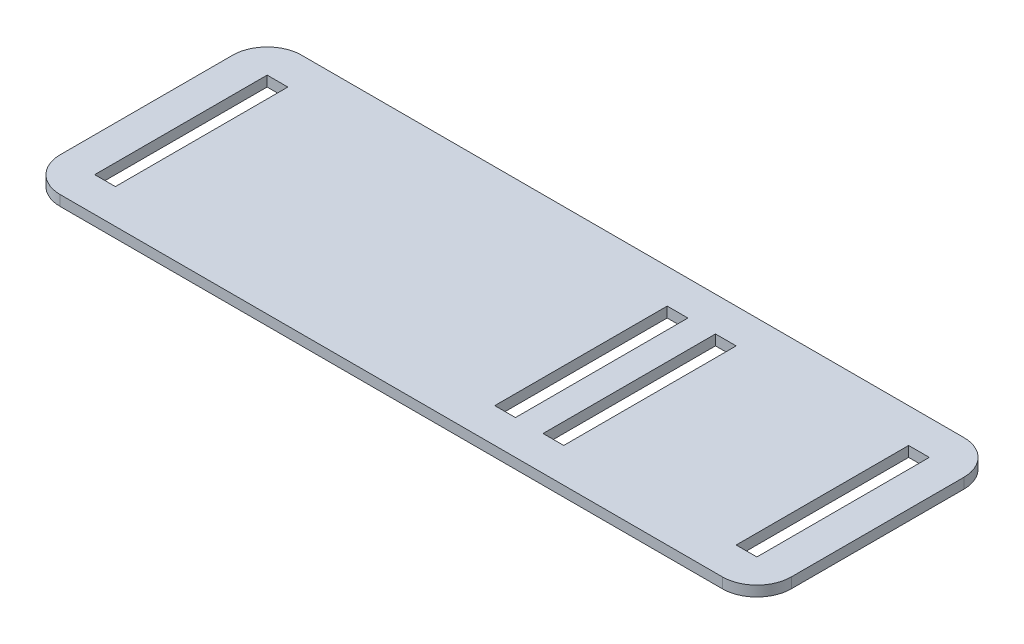
from build123d import *

# Parameters (mm, degrees)
SKETCH1_W               = 212
SKETCH1_H               = 70
BOSS_EXTRUDE1_DEPTH     = 3
SKETCH2_W               = 6
SKETCH2_H               = 50
CUT_EXTRUDE1_DEPTH      = 1
CUT_EXTRUDE1_DEPTH_BACK = 4
FILLET1_R               = 10


with BuildPart() as part:
    # Sketch1 → Boss-Extrude1 (new body)
    with BuildSketch(Plane(origin=(0, 0, 0), x_dir=(1, 0, 0), z_dir=(0, 1, 0))):
        Rectangle(SKETCH1_W, SKETCH1_H)
    extrude(amount=BOSS_EXTRUDE1_DEPTH)

    # Sketch2 → Cut-Extrude1 (cut, two sides)
    with BuildSketch(Plane(origin=(0, 3, 0), x_dir=(1, 0, 0), z_dir=(0, 1, 0))) as cut_extrude1_sk:
        with Locations((23, 0)):
            Rectangle(SKETCH2_W, SKETCH2_H)
        with Locations((-93, 0)):
            Rectangle(SKETCH2_W, SKETCH2_H)
        with Locations((37, 0)):
            Rectangle(SKETCH2_W, SKETCH2_H)
        with Locations((93, 0)):
            Rectangle(SKETCH2_W, SKETCH2_H)
    extrude(amount=CUT_EXTRUDE1_DEPTH, mode=Mode.SUBTRACT)
    extrude(cut_extrude1_sk.sketch, amount=-CUT_EXTRUDE1_DEPTH_BACK, mode=Mode.SUBTRACT)

    # Fillet1
    fillet1_edges = [part.edges().sort_by_distance(p)[0] for p in [
        (106, 1.5, 35),
        (-106, 1.5, 35),
        (-106, 1.5, -35),
        (106, 1.5, -35),
    ]]
    fillet(fillet1_edges, radius=FILLET1_R)


solid = part.part
